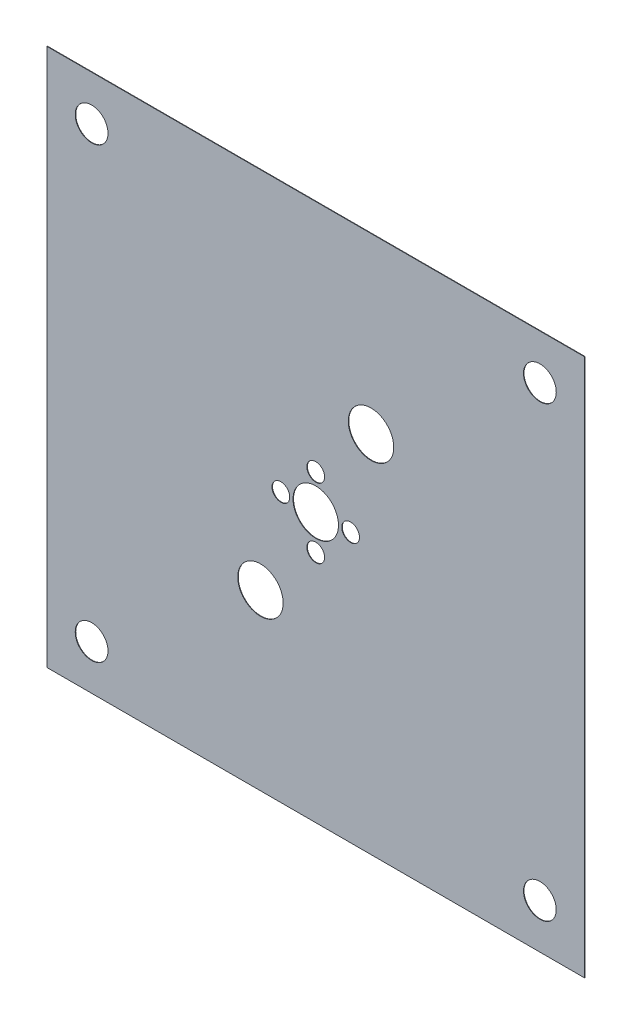
from build123d import *

# Parameters (mm, degrees)
SKETCH1_W           = 2160
SKETCH1_H           = 2160
SKETCH1_R           = 91.2
SKETCH1_R_2         = 35.6375
SKETCH1_R_3         = 65.8
BOSS_EXTRUDE1_DEPTH = 2


with BuildPart() as part:
    # Sketch1 → Boss-Extrude1 (new body)
    with BuildSketch(Plane.XY):
        Rectangle(SKETCH1_W, SKETCH1_H)
        Circle(SKETCH1_R, mode=Mode.SUBTRACT)
        with Locations((0, 140)):
            Circle(SKETCH1_R_2, mode=Mode.SUBTRACT)
        with Locations((222, 382)):
            Circle(SKETCH1_R, mode=Mode.SUBTRACT)
        with Locations((-222, -382)):
            Circle(SKETCH1_R, mode=Mode.SUBTRACT)
        with Locations((-900, 900)):
            Circle(SKETCH1_R_3, mode=Mode.SUBTRACT)
        with Locations((900, -900)):
            Circle(SKETCH1_R_3, mode=Mode.SUBTRACT)
        with Locations((900, 900)):
            Circle(SKETCH1_R_3, mode=Mode.SUBTRACT)
        with Locations((-900, -900)):
            Circle(SKETCH1_R_3, mode=Mode.SUBTRACT)
        with Locations((0, -140)):
            Circle(SKETCH1_R_2, mode=Mode.SUBTRACT)
        with Locations((140, 0)):
            Circle(SKETCH1_R_2, mode=Mode.SUBTRACT)
        with Locations((-140, 0)):
            Circle(SKETCH1_R_2, mode=Mode.SUBTRACT)
    extrude(amount=BOSS_EXTRUDE1_DEPTH)


solid = part.part
